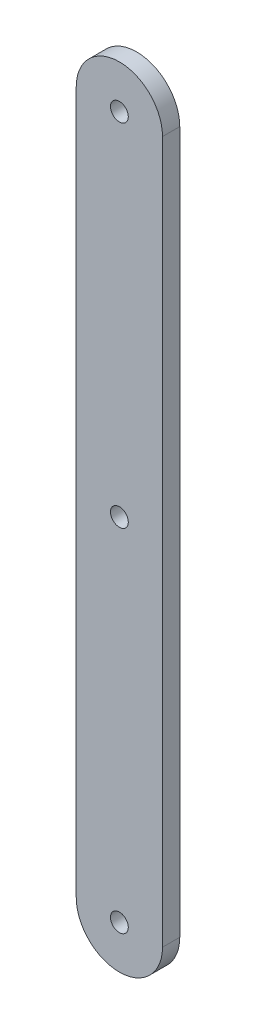
from build123d import *

# Parameters (mm, degrees)
CROQUIS1_R              = 1.55
SALIENTE_EXTRUIR1_DEPTH = 3


with BuildPart() as part:
    # Croquis1 → Saliente-Extruir1 (new body)
    with BuildSketch(Plane.XY):
        with BuildLine():
            Line((-7.5, 0), (-7.5, 122.06))
            ThreePointArc((-7.5, 122.06), (0, 129.56), (7.5, 122.06))
            Line((7.5, 122.06), (7.5, 0))
            ThreePointArc((7.5, 0), (0, -7.5), (-7.5, 0))
        make_face()
        Circle(CROQUIS1_R, mode=Mode.SUBTRACT)
        with Locations((0, 122.06)):
            Circle(CROQUIS1_R, mode=Mode.SUBTRACT)
        with Locations((0, 61.03)):
            Circle(CROQUIS1_R, mode=Mode.SUBTRACT)
    extrude(amount=SALIENTE_EXTRUIR1_DEPTH)


solid = part.part
